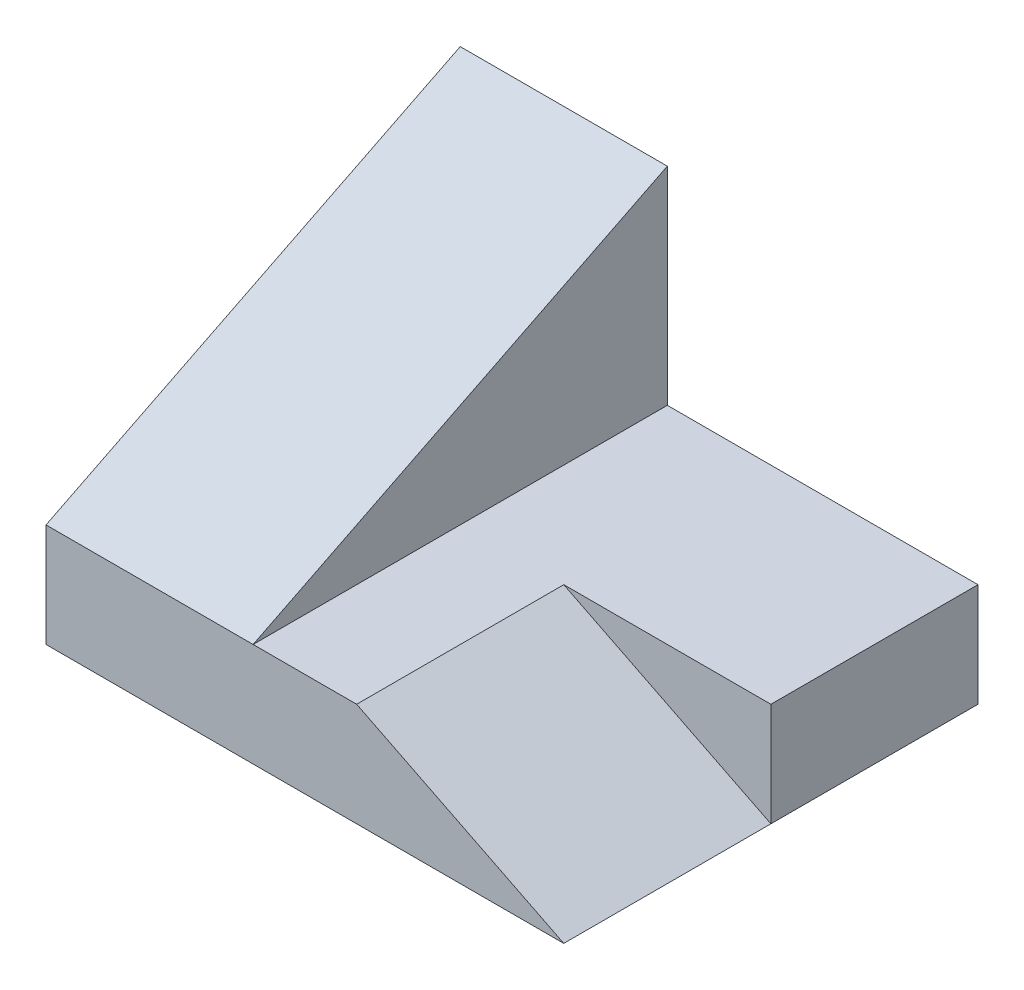
from build123d import *

# Parameters (mm, degrees)
SKETCH1_W           = 50
SKETCH1_H           = 40
BOSS_EXTRUDE1_DEPTH = 30
SKETCH2_W           = 30
SKETCH2_H           = 40
CUT_EXTRUDE1_DEPTH  = 20
CUT_EXTRUDE2_DEPTH  = 20
CUT_EXTRUDE3_DEPTH  = 20


with BuildPart() as part:
    # Sketch1 → Boss-Extrude1 (new body)
    with BuildSketch(Plane(origin=(0, 0, 0), x_dir=(1, 0, 0), z_dir=(0, 1, 0))):
        with Locations((25, 20)):
            Rectangle(SKETCH1_W, SKETCH1_H)
    extrude(amount=BOSS_EXTRUDE1_DEPTH)

    # Sketch2 → Cut-Extrude1 (cut)
    with BuildSketch(Plane(origin=(0, 30, 0), x_dir=(1, 0, 0), z_dir=(0, 1, 0))):
        with Locations((35, 20)):
            Rectangle(SKETCH2_W, SKETCH2_H)
    extrude(amount=-CUT_EXTRUDE1_DEPTH, mode=Mode.SUBTRACT)

    # Sketch4 → Cut-Extrude2 (cut)
    with BuildSketch(Plane(origin=(20, 0, 0), x_dir=(0, 0, -1), z_dir=(1, 0, 0))):
        Polygon((40, 30), (0, 10), (0, 30), align=None)
    extrude(amount=-CUT_EXTRUDE2_DEPTH, mode=Mode.SUBTRACT)

    # Sketch5 → Cut-Extrude3 (cut)
    with BuildSketch(Plane.XY):
        Polygon((50, 0), (30, 10), (50, 10), align=None)
    extrude(amount=-CUT_EXTRUDE3_DEPTH, mode=Mode.SUBTRACT)


solid = part.part
